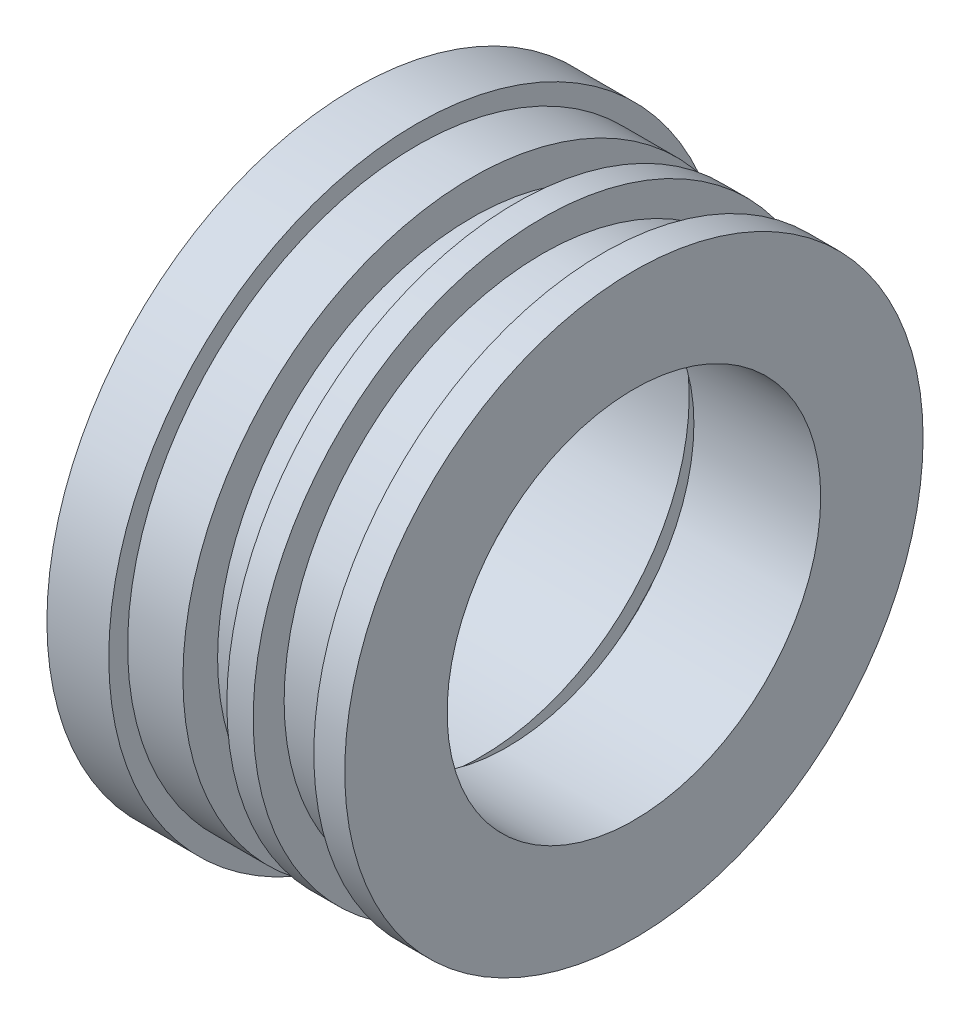
from build123d import *

# Parameters (mm, degrees)
F_1_32_0_03125_DIAMETER_HOLE1_REACH  = 30.292
F_1_32_0_03125_DIAMETER_HOLE1_BORE_R = 0.396875


with BuildPart() as part:
    # Sketch1 → Revolve1 (revolve)
    with BuildSketch(Plane.XY, mode=Mode.PRIVATE) as revolve1_sk:
        Polygon((-6.2484, 12.6492), (-6.2484, 8.550800018), (-1.073308102, 8.550800018), (-1.073308102, 9.17149847), (0, 9.17149847), (0, 8.550800018), (0, 7.6708), (5.207, 7.6708), (5.207, 11.8745), (3.937, 11.8745), (3.937, 10.6045), (1.4478, 10.6045), (1.4478, 11.8745), (-3.7084, 11.8745), (-3.7084, 12.6492), align=None)
    revolve(revolve1_sk.sketch.rotate(Axis((0, 0, 0), (-1, 0, 0)), 90), axis=Axis((0, 0, 0), (-1, 0, 0)))

    # 1/32 (0.03125) Diameter Hole1 bore → 1/32 (0.03125) Diameter Hole1 (cut, up to next)
    with BuildSketch(Plane(origin=(0, 11.8745, 0), x_dir=(1, 0, 0), z_dir=(0, 1, 0)), mode=Mode.PRIVATE) as f_1_32_0_03125_diameter_hole1_sk1:
        with Locations((-0.536654051, 0)):
            Circle(F_1_32_0_03125_DIAMETER_HOLE1_BORE_R)
    f_1_32_0_03125_diameter_hole1_tool1 = extrude(f_1_32_0_03125_diameter_hole1_sk1.sketch, amount=-F_1_32_0_03125_DIAMETER_HOLE1_REACH, mode=Mode.PRIVATE) & part.part
    add(f_1_32_0_03125_diameter_hole1_tool1.solids().sort_by_distance((-0.536654, 11.8745, 0))[0], mode=Mode.SUBTRACT)

    # Sketch4 → Cut-Revolve3 (revolve, cut)
    with BuildSketch(Plane.XY, mode=Mode.PRIVATE) as cut_revolve3_sk:
        with BuildLine():
            Line((-0.139779051, 11.8745), (0.364997855, 11.8745))
            Line((0.364997855, 11.8745), (0.364997855, 10.450394686))
            Line((0.364997855, 10.450394686), (-1.438305958, 10.450394686))
            Line((-1.438305958, 10.450394686), (-1.438305958, 11.8745))
            Line((-1.438305958, 11.8745), (-0.933529051, 11.8745))
            add(Edge.make_bspline(
                [(-0.139779051, 11.8745), (-0.536654051, 11.861235461), (-0.933529051, 11.8745)],
                knots=[0, 0, 0, 1, 1, 1], degree=2, weights=[0.011477625, 0.0118745, 0.012271375]))
        make_face()
    revolve(cut_revolve3_sk.sketch.rotate(Axis((-6.82117, 0, 0), (1, 0, 0)), 270), axis=Axis((-6.82117, 0, 0), (1, 0, 0)), mode=Mode.SUBTRACT)


with BuildPart() as cut_revolve3_kept_piece:
    # of the separate pieces the step leaves, the one the design keeps (cut_revolve3_pieces_kept)
    add(part.part.solids().sort_by_distance((-6.2484, 0, -12.6492))[0])


solid = cut_revolve3_kept_piece.part
